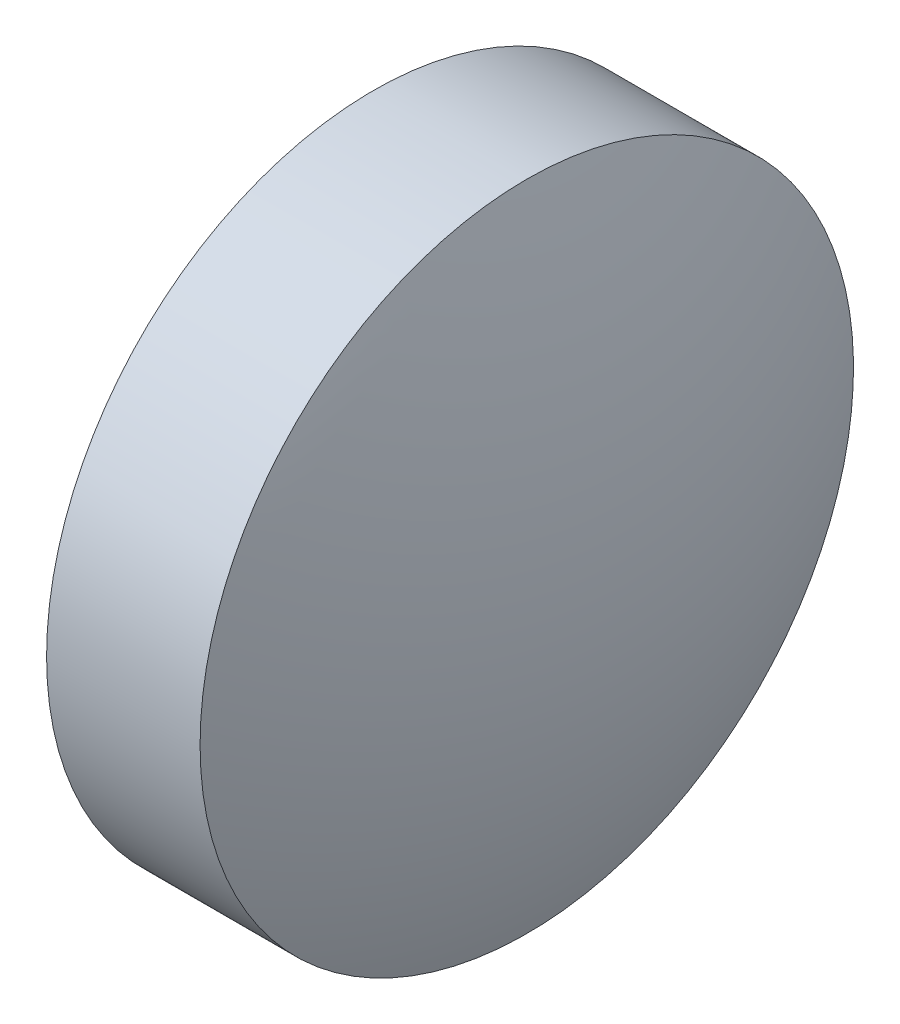
from build123d import *


with BuildPart() as part:
    # 草图1 → 旋转1 (revolve)
    with BuildSketch(Plane.XY):
        with BuildLine():
            Line((22.594743036, 13.004189076), (22.594743036, 16.154189076))
            Line((22.594743036, 16.154189076), (24.074743036, 16.154189076))
            ThreePointArc((24.074743036, 16.154189076), (24.538270244, 14.60940713), (24.694743036, 13.004189076))
            Line((24.694743036, 13.004189076), (22.594743036, 13.004189076))
        make_face()
    revolve(axis=Axis((21.733114866, 13.004189076, 0), (1, 0, 0)))


solid = part.part
